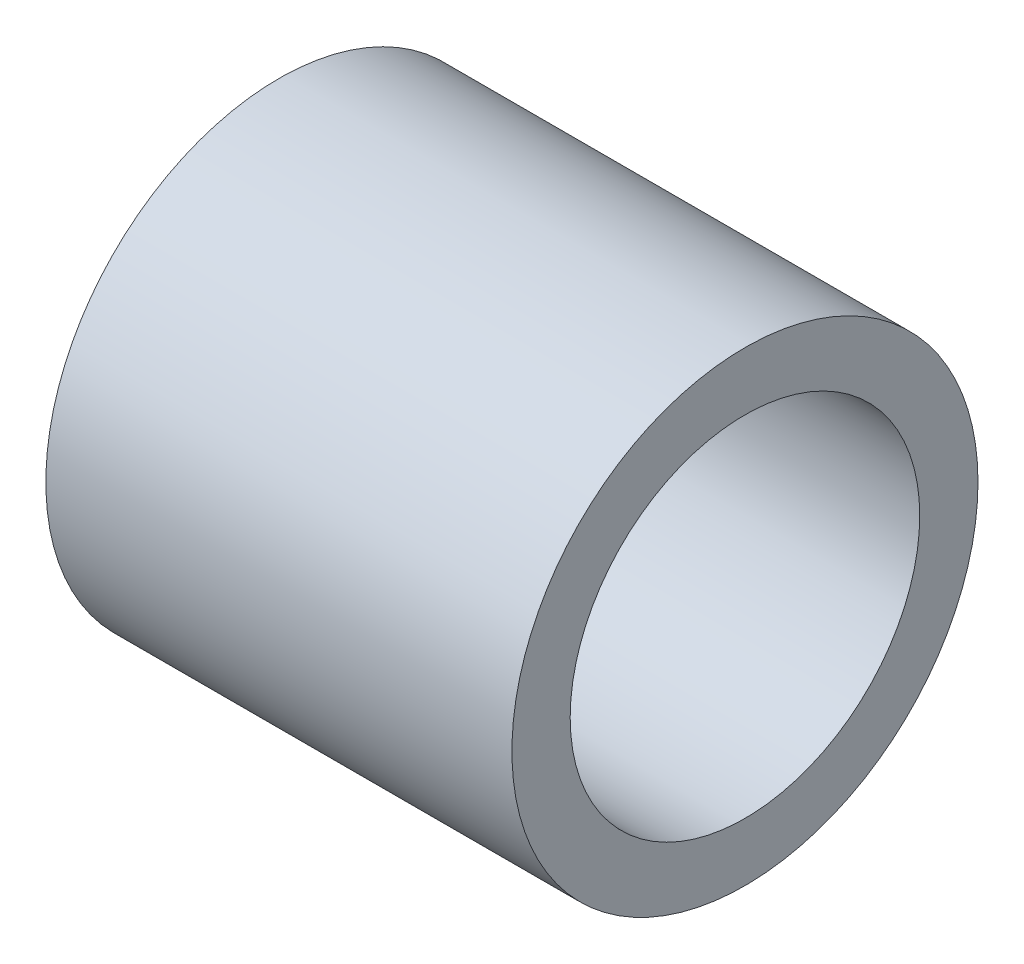
from build123d import *

# Parameters (mm, degrees)
SKETCH1_R           = 12.7
SKETCH1_R_2         = 9.525
BOSS_EXTRUDE1_DEPTH = 12.7


with BuildPart() as part:
    # Sketch1 → Boss-Extrude1 (new body, symmetric)
    with BuildSketch(Plane(origin=(0, 0, 0), x_dir=(0, 0, -1), z_dir=(1, 0, 0))):
        Circle(SKETCH1_R)
        Circle(SKETCH1_R_2, mode=Mode.SUBTRACT)
    extrude(amount=BOSS_EXTRUDE1_DEPTH, both=True)


solid = part.part
